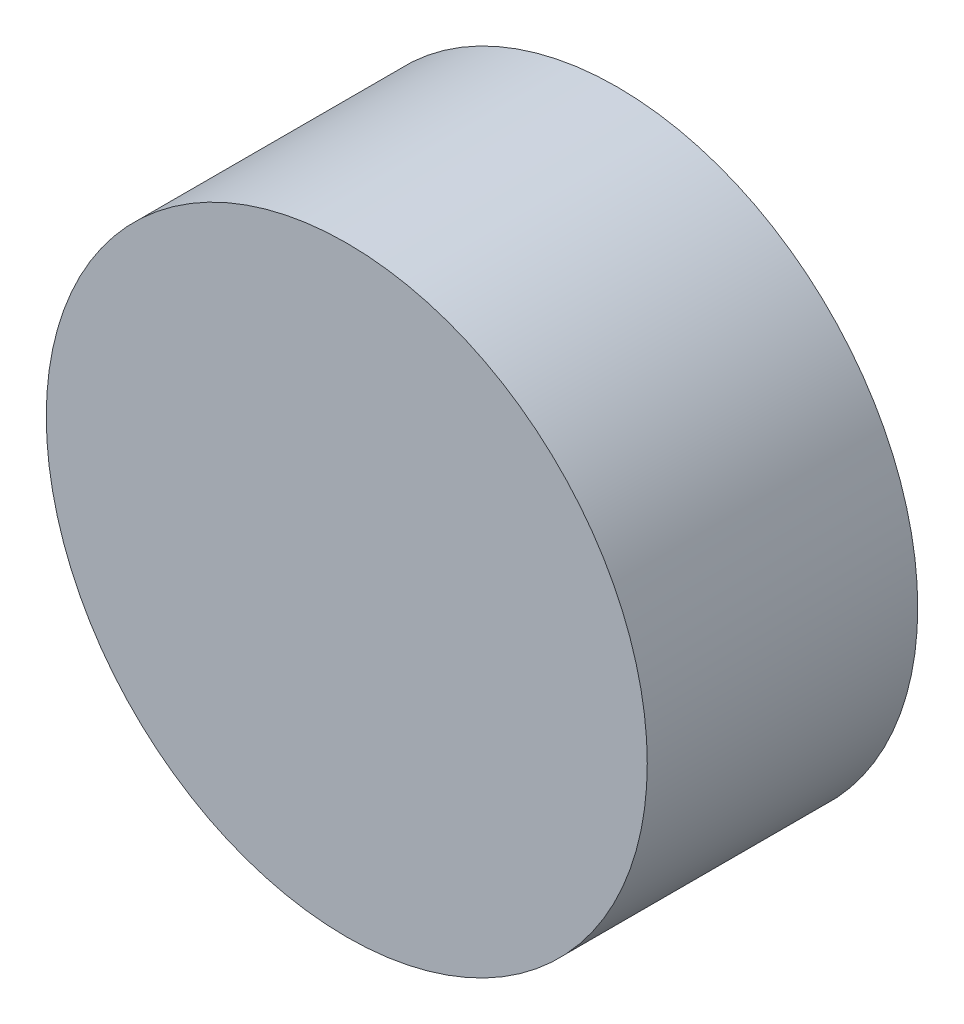
from build123d import *

# Parameters (mm, degrees)
SKETCH1_R           = 10
BOSS_EXTRUDE1_DEPTH = 9


with BuildPart() as part:
    # Sketch1 → Boss-Extrude1 (new body)
    with BuildSketch(Plane.XY):
        with Locations((0, -151.01)):
            Circle(SKETCH1_R)
    extrude(amount=BOSS_EXTRUDE1_DEPTH)


solid = part.part
